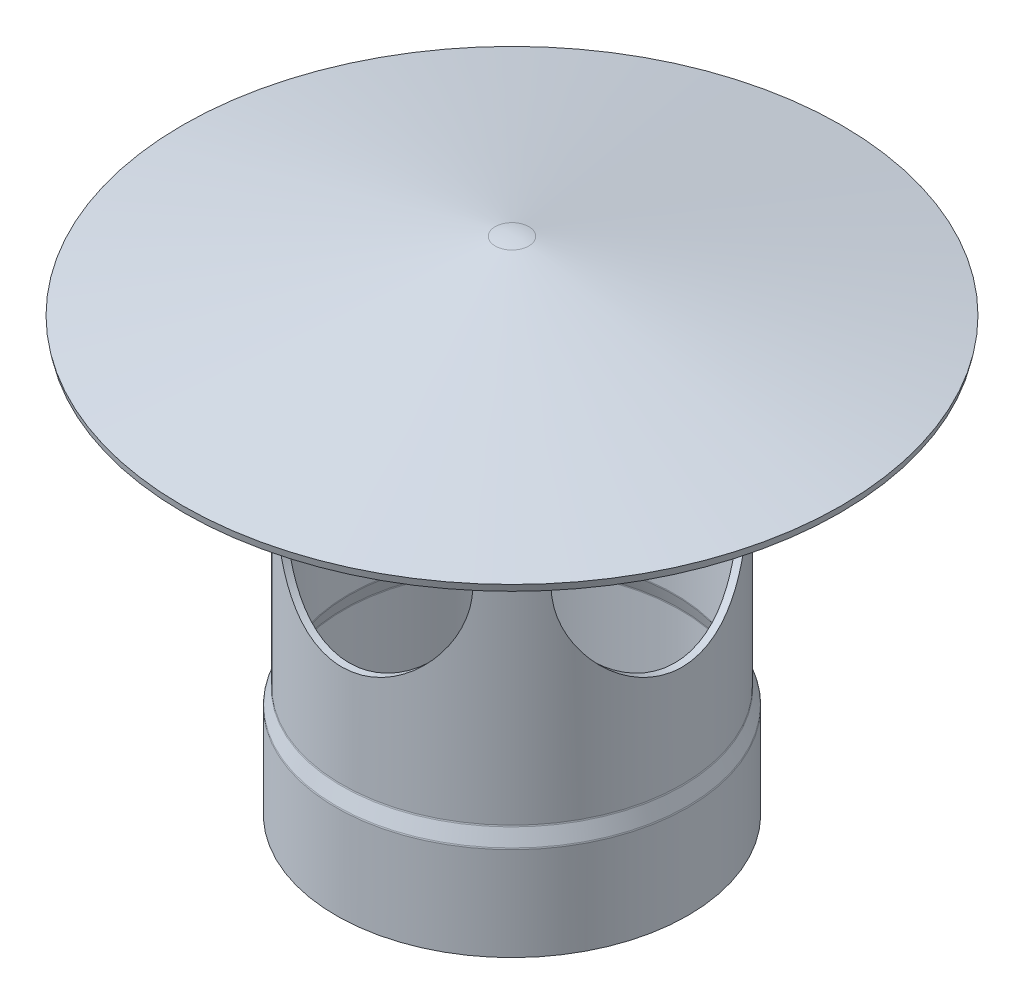
from build123d import *

# Parameters (mm, degrees)
CUT_EXTRUDE1_REACH             = 634.259
SKETCH2_RX                     = 84.1375
SKETCH2_RY                     = 80.16875
CUT_EXTRUDE1_DIRECTION_2_DEPTH = 50.8
CIRPATTERN1_COUNT              = 4
FILLET3_R                      = 3.175


with BuildPart() as part:
    # Sketch1 → Revolve1 (revolve)
    with BuildSketch(Plane.XY, mode=Mode.PRIVATE) as revolve1_sk:
        with BuildLine():
            Line((-142.367, 0), (-142.367, 76.2))
            Line((-142.367, 76.2), (-137.6045, 88.9))
            Line((-137.6045, 88.9), (-137.6045, 371.7828091))
            Line((-137.6045, 371.7828091), (-265.449948313, 343.778246145))
            Line((-265.449948313, 343.778246145), (-266.7, 349.48493825))
            Line((-266.7, 349.48493825), (-13.587518335, 404.92926201))
            ThreePointArc((-13.587518335, 404.92926201), (-6.833442118, 406.031244791), (0, 406.4))
            Line((0, 406.4), (0, 401.925093663))
            Line((0, 401.925093663), (-119.34342038, 375.782901091))
            Line((-119.34342038, 375.782901091), (0, 343.804927978))
            Line((0, 343.804927978), (0, 338.204852024))
            ThreePointArc((0, 338.204852024), (-1.657682641, 338.313502284), (-3.287001873, 338.63759403))
            Line((-3.287001873, 338.63759403), (-131.7625, 373.0625))
            Line((-131.7625, 373.0625), (-131.7625, 87.840643373))
            Line((-131.7625, 87.840643373), (-136.525, 75.140643373))
            Line((-136.525, 75.140643373), (-136.525, 0))
            Line((-136.525, 0), (-142.367, 0))
        make_face()
    revolve(revolve1_sk.sketch.rotate(Axis((0, -82.737615653, 0), (0, 1, 0)), 180), axis=Axis((0, -82.737615653, 0), (0, 1, 0)))

    # Sketch2 → Cut-Extrude1 (cut, up to next)
    with BuildSketch(Plane.XY.offset(137.6045), mode=Mode.PRIVATE) as cut_extrude1_sk1:
        with Locations(Location((0, 255.8953091), (0, 0, -90))):
            Ellipse(SKETCH2_RX, SKETCH2_RY)
    cut_extrude1_tool1 = extrude(cut_extrude1_sk1.sketch, amount=-CUT_EXTRUDE1_REACH, mode=Mode.PRIVATE) & part.part
    cut_extrude1 = cut_extrude1_tool1.solids().sort_by_distance((0, 255.895309, 137.6045))[0]
    add(cut_extrude1, mode=Mode.SUBTRACT)

    # Sketch2 → Cut-Extrude1 direction 2 (cut)
    with BuildSketch(Plane.XY.offset(137.6045)):
        with Locations(Location((0, 255.8953091), (0, 0, -90))):
            Ellipse(SKETCH2_RX, SKETCH2_RY)
    cut_extrude1_direction_2 = extrude(amount=CUT_EXTRUDE1_DIRECTION_2_DEPTH, mode=Mode.SUBTRACT)

    # CirPattern1: Cut-Extrude1, Cut-Extrude1 direction 2 ×4 about axis
    cirpattern1_axis = Axis((0, -82.737615653, 0), (0, -1, 0))
    add([cut_extrude1.rotate(cirpattern1_axis, i * 360 / CIRPATTERN1_COUNT) for i in range(1, CIRPATTERN1_COUNT)], mode=Mode.SUBTRACT)
    add([cut_extrude1_direction_2.rotate(cirpattern1_axis, i * 360 / CIRPATTERN1_COUNT) for i in range(1, CIRPATTERN1_COUNT)], mode=Mode.SUBTRACT)

    # Fillet3
    fillet3_edges = [part.edges().sort_by_distance(p)[0] for p in [
        (-142.367, 76.2, 0),
        (-137.6045, 88.9, 0),
        (-131.7625, 87.840643373, 0),
        (-136.525, 75.140643373, 0),
    ]]
    fillet(fillet3_edges, radius=FILLET3_R)


solid = part.part
